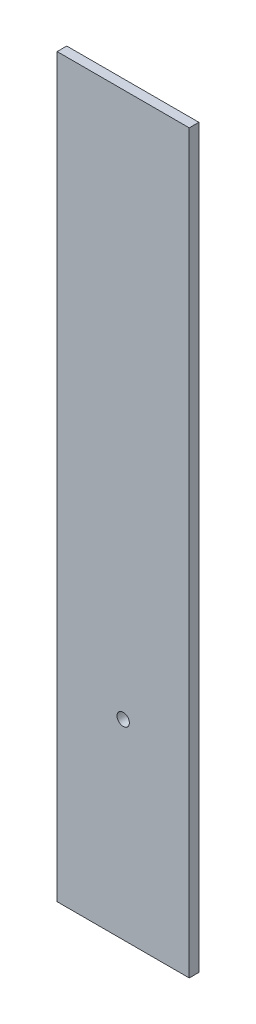
from build123d import *

# Parameters (mm, degrees)
SKETCH1_W           = 68
SKETCH1_H           = 378.959461552
SKETCH1_R           = 3.175
BOSS_EXTRUDE1_DEPTH = 4.953


with BuildPart() as part:
    # Sketch1 → Boss-Extrude1 (new body)
    with BuildSketch(Plane.XY):
        with Locations((0, 205.479730776)):
            Rectangle(SKETCH1_W, SKETCH1_H)
        with Locations((0, 114.3)):
            Circle(SKETCH1_R, mode=Mode.SUBTRACT)
    extrude(amount=BOSS_EXTRUDE1_DEPTH)


solid = part.part
